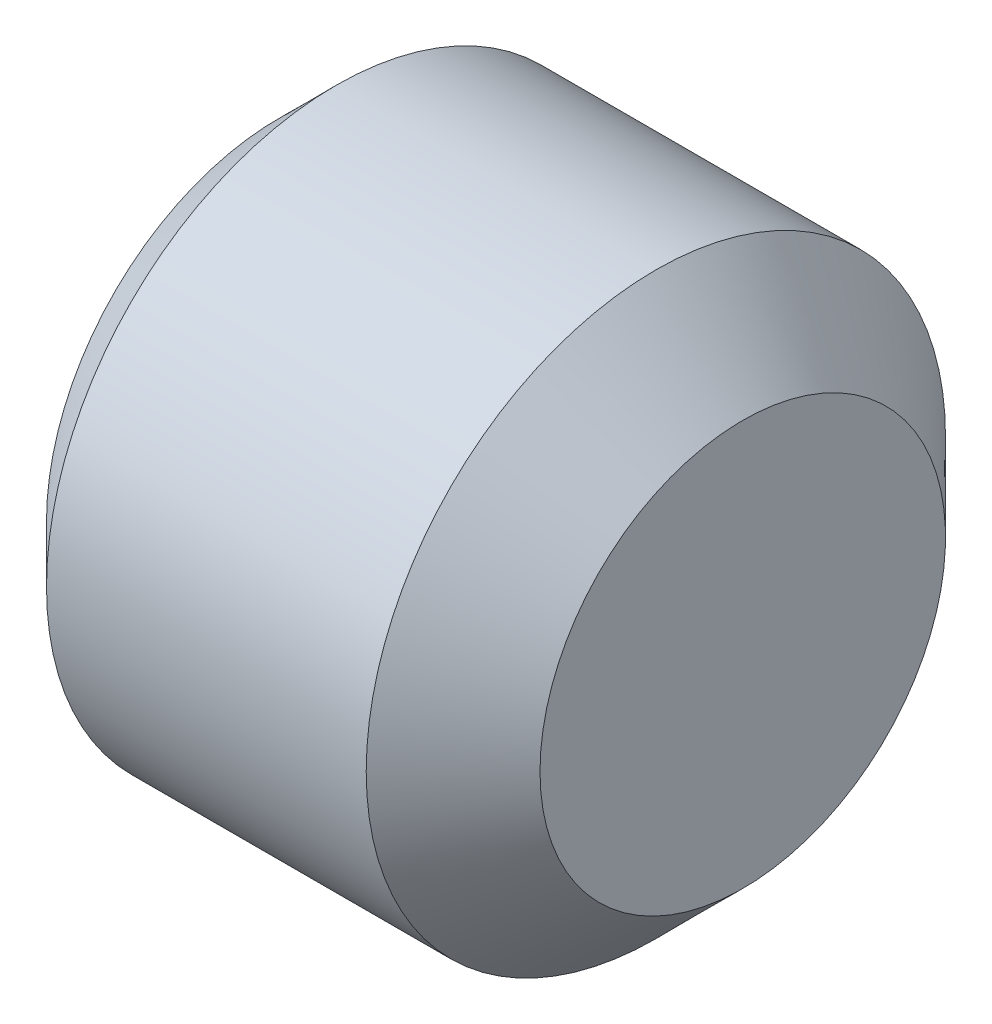
from build123d import *

# Parameters (mm, degrees)
CUT_EXTRUDE_1_DEPTH = 2


with BuildPart() as part:
    # ｽｹｯﾁ1 → 回転1 (revolve)
    with BuildSketch(Plane.XY):
        Polygon((-4, 0), (-4, 2.0095), (-3.5095, 2.5), (-0.75, 2.5), (0, 1.75), (0, 0), align=None)
    revolve(axis=Axis((0, 0, 0), (-1, 0, 0)))

    # ｽｹｯﾁ2 → ｶｯﾄ - 押し出し1 (cut)
    with BuildSketch(Plane.ZY.offset(4)):
        Polygon((0.721687836, -1.25), (1.443375673, 0), (0.721687836, 1.25), (-0.721687836, 1.25), (-1.443375673, 0), (-0.721687836, -1.25), align=None)
    extrude(amount=-CUT_EXTRUDE_1_DEPTH, mode=Mode.SUBTRACT)

    # ｽｹｯﾁ3 → ｶｯﾄ - 回転1 (revolve, cut)
    with BuildSketch(Plane.XY):
        Polygon((-2, 0), (-2, 1.25), (-1.278312164, 0), align=None)
    revolve(axis=Axis((-1.278312164, 0, 0), (-1, 0, 0)), mode=Mode.SUBTRACT)


solid = part.part
